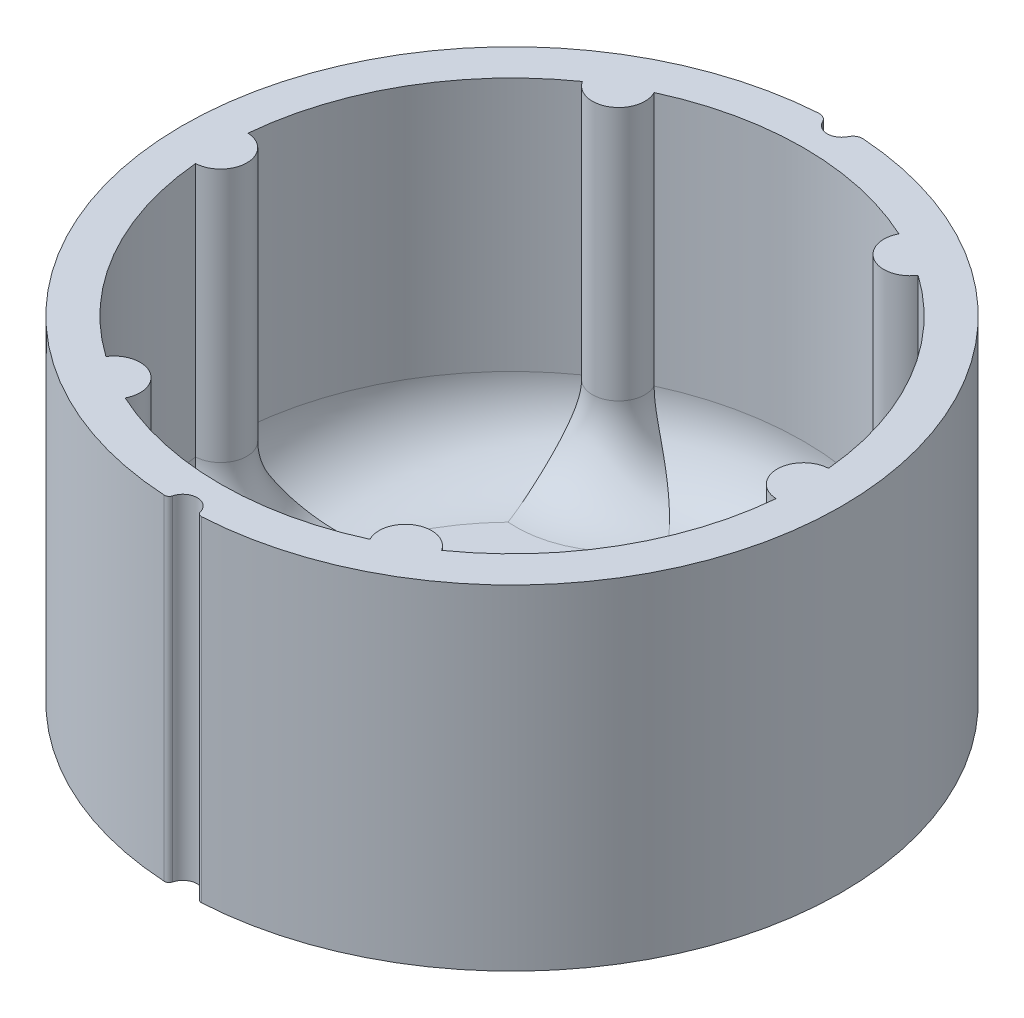
from build123d import *

# Parameters (mm, degrees)
BOSS_EXTRUDE1_DEPTH = 35
CUT_EXTRUDE2_DEPTH  = 61.012997416
BOSS_EXTRUDE2_DEPTH = 0.4
FILLET1_R           = 8


with BuildPart() as part:
    # Sketch1 → Boss-Extrude1 (new body)
    with BuildSketch(Plane(origin=(0, 0, 0), x_dir=(1, 0, 0), z_dir=(0, 1, 0))):
        with BuildLine():
            ThreePointArc((1.451818925, -34.068556857), (1.641248992, -34.346908706), (1.964225605, -34.442038138))
            ThreePointArc((1.964225605, -34.442038138), (26.591847487, -21.978073076), (34.198225299, 4.555174015))
            ThreePointArc((34.198225299, 4.555174015), (23.590291339, 25.176355888), (2.324135821, 34.423627607))
            ThreePointArc((2.324135821, 34.423627607), (1.751838249, 34.289058819), (1.354061739, 33.856153382))
            ThreePointArc((1.354061739, 33.856153382), (0, 33.001534515), (-1.354061739, 33.856153382))
            ThreePointArc((-1.354061739, 33.856153382), (-1.751838249, 34.289058819), (-2.324135821, 34.423627607))
            ThreePointArc((-2.324135821, 34.423627607), (-23.590291339, 25.176355888), (-34.198225299, 4.555174015))
            ThreePointArc((-34.198225299, 4.555174015), (-26.591847487, -21.978073076), (-1.964225605, -34.442038138))
            ThreePointArc((-1.964225605, -34.442038138), (-1.641248992, -34.346908706), (-1.451818925, -34.068556857))
            ThreePointArc((-1.451818925, -34.068556857), (0, -32.945679925), (1.451818925, -34.068556857))
        make_face()
        with BuildLine():
            Line((-2.417, 3.787737139), (0, 3.787737139))
            Line((0, 3.787737139), (2.417, 3.787737139))
            ThreePointArc((2.417, 3.787737139), (0, -4.489512172), (-2.417, 3.787737139))
        make_face(mode=Mode.SUBTRACT)
    extrude(amount=BOSS_EXTRUDE1_DEPTH)

    # Sketch2 → Cut-Extrude2 (cut, through all)
    with BuildSketch(Plane(origin=(0, 0, 0), x_dir=(1, 0, 0), z_dir=(0, 1, 0))):
        with BuildLine():
            ThreePointArc((-17.567160793, 24.932806936), (-26.413774815, 15.25), (-30.37602459, 2.747204051))
            ThreePointArc((-30.37602459, 2.747204051), (-27.75, 0), (-30.37602459, -2.747204051))
            ThreePointArc((-30.37602459, -2.747204051), (-26.413774815, -15.25), (-17.567160793, -24.932806936))
            ThreePointArc((-17.567160793, -24.932806936), (-13.875, -24.032204955), (-12.808863798, -27.680010987))
            ThreePointArc((-12.808863798, -27.680010987), (0, -30.5), (12.808863798, -27.680010987))
            ThreePointArc((12.808863798, -27.680010987), (13.875, -24.032204955), (17.567160793, -24.932806936))
            ThreePointArc((17.567160793, -24.932806936), (26.413774815, -15.25), (30.37602459, -2.747204051))
            ThreePointArc((30.37602459, -2.747204051), (27.75, 0), (30.37602459, 2.747204051))
            ThreePointArc((30.37602459, 2.747204051), (26.413774815, 15.25), (17.567160793, 24.932806936))
            ThreePointArc((17.567160793, 24.932806936), (13.875, 24.032204955), (12.808863798, 27.680010987))
            ThreePointArc((12.808863798, 27.680010987), (0, 30.5), (-12.808863798, 27.680010987))
            ThreePointArc((-12.808863798, 27.680010987), (-13.875, 24.032204955), (-17.567160793, 24.932806936))
        make_face()
    extrude(amount=CUT_EXTRUDE2_DEPTH, mode=Mode.SUBTRACT)

    # Sketch2_2 → Boss-Extrude2 (add)
    with BuildSketch(Plane(origin=(0, 0, 0), x_dir=(1, 0, 0), z_dir=(0, 1, 0))):
        with BuildLine():
            ThreePointArc((-17.567160793, 24.932806936), (-26.413774815, 15.25), (-30.37602459, 2.747204051))
            ThreePointArc((-30.37602459, 2.747204051), (-27.75, 0), (-30.37602459, -2.747204051))
            ThreePointArc((-30.37602459, -2.747204051), (-26.413774815, -15.25), (-17.567160793, -24.932806936))
            ThreePointArc((-17.567160793, -24.932806936), (-13.875, -24.032204955), (-12.808863798, -27.680010987))
            ThreePointArc((-12.808863798, -27.680010987), (0, -30.5), (12.808863798, -27.680010987))
            ThreePointArc((12.808863798, -27.680010987), (13.875, -24.032204955), (17.567160793, -24.932806936))
            ThreePointArc((17.567160793, -24.932806936), (26.413774815, -15.25), (30.37602459, -2.747204051))
            ThreePointArc((30.37602459, -2.747204051), (27.75, 0), (30.37602459, 2.747204051))
            ThreePointArc((30.37602459, 2.747204051), (26.413774815, 15.25), (17.567160793, 24.932806936))
            ThreePointArc((17.567160793, 24.932806936), (13.875, 24.032204955), (12.808863798, 27.680010987))
            ThreePointArc((12.808863798, 27.680010987), (0, 30.5), (-12.808863798, 27.680010987))
            ThreePointArc((-12.808863798, 27.680010987), (-13.875, 24.032204955), (-17.567160793, 24.932806936))
        make_face()
    extrude(amount=BOSS_EXTRUDE2_DEPTH)

    # Fillet1
    fillet1_edges = [part.edges().sort_by_distance(p)[0] for p in [
        (13.875, 0.4, 24.032204955),
        (0, 0.4, 30.5),
        (-13.875, 0.4, 24.032204955),
        (-26.413774815, 0.4, 15.25),
        (-27.75, 0.4, 0),
        (-26.413774815, 0.4, -15.25),
        (-13.875, 0.4, -24.032204955),
        (0, 0.4, -30.5),
        (13.875, 0.4, -24.032204955),
        (26.413774815, 0.4, -15.25),
        (27.75, 0.4, 0),
        (26.413774815, 0.4, 15.25),
    ]]
    fillet(fillet1_edges, radius=FILLET1_R)


solid = part.part
